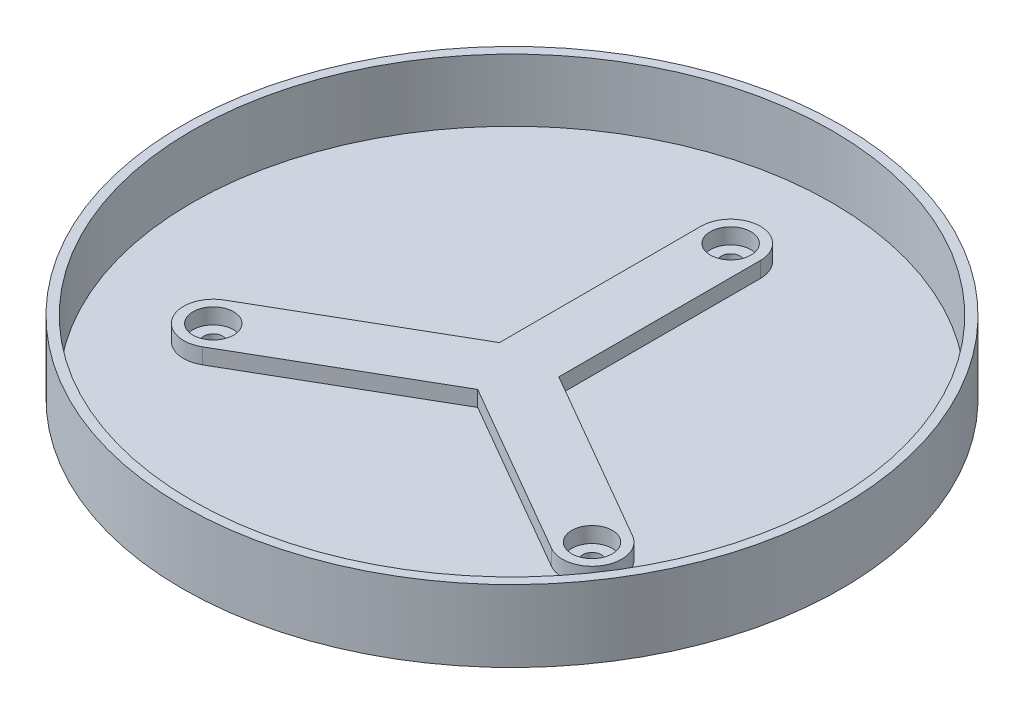
from build123d import *

# Parameters (mm, degrees)
SKETCH1_R               = 102.5
BOSS_EXTRUDE2_DEPTH     = 20
SHELL3_T                = 3
SKETCH3_R               = 6.5
BOSS_EXTRUDE8_DEPTH     = 5
SKETCH5_R               = 3
CUT_EXTRUDE2_DEPTH      = 151.534049304
CUT_EXTRUDE2_DEPTH_BACK = 151.534049304


with BuildPart() as part:
    # Sketch1 → Boss-Extrude2 (new body)
    with BuildSketch(Plane(origin=(0, 0, 0), x_dir=(1, 0, 0), z_dir=(0, 1, 0))):
        with Locations(Location((0, 0, 0), (0, 0, 270))):
            Circle(SKETCH1_R)
    extrude(amount=BOSS_EXTRUDE2_DEPTH)

    # Shell3
    shell3_openings = [part.faces().sort_by_distance(p)[0] for p in [
        (0, 20, 0),
    ]]
    offset(amount=SHELL3_T, openings=shell3_openings, kind=Kind.INTERSECTION)

    # Sketch3 → Boss-Extrude8 (add)
    with BuildSketch(Plane(origin=(0, 0, 0), x_dir=(1, 0, 0), z_dir=(0, 1, 0))):
        with BuildLine():
            ThreePointArc((9.5, 70), (0, 79.5), (-9.5, 70))
            Line((-9.5, 70), (-9.5, 5.484827557))
            Line((-9.5, 5.484827557), (-65.371778265, -26.772758664))
            ThreePointArc((-65.371778265, -26.772758664), (-68.849019601, -39.75), (-55.871778265, -43.227241336))
            Line((-55.871778265, -43.227241336), (0, -10.969655115))
            Line((0, -10.969655115), (55.871778265, -43.227241336))
            ThreePointArc((55.871778265, -43.227241336), (68.849019601, -39.75), (65.371778265, -26.772758664))
            Line((65.371778265, -26.772758664), (9.5, 5.484827557))
            Line((9.5, 5.484827557), (9.5, 70))
        make_face()
        with Locations(Location((-60.621778265, -35, 0), (0, 0, 270))):
            Circle(SKETCH3_R, mode=Mode.SUBTRACT)
        with Locations(Location((60.621778265, -35, 0), (0, 0, 270))):
            Circle(SKETCH3_R, mode=Mode.SUBTRACT)
        with Locations(Location((0, 70, 0), (0, 0, 270))):
            Circle(SKETCH3_R, mode=Mode.SUBTRACT)
    extrude(amount=BOSS_EXTRUDE8_DEPTH)

    # Sketch5 → Cut-Extrude2 (cut, two sides)
    with BuildSketch(Plane(origin=(0, 0, 0), x_dir=(1, 0, 0), z_dir=(0, 1, 0))) as cut_extrude2_sk:
        with Locations(Location((0, 70, 0), (0, 0, 270))):
            Circle(SKETCH5_R)
        with Locations(Location((60.621778265, -35, 0), (0, 0, 270))):
            Circle(SKETCH5_R)
        with Locations(Location((-60.621778265, -35, 0), (0, 0, 270))):
            Circle(SKETCH5_R)
    extrude(amount=CUT_EXTRUDE2_DEPTH, mode=Mode.SUBTRACT)
    extrude(cut_extrude2_sk.sketch, amount=-CUT_EXTRUDE2_DEPTH_BACK, mode=Mode.SUBTRACT)


solid = part.part
